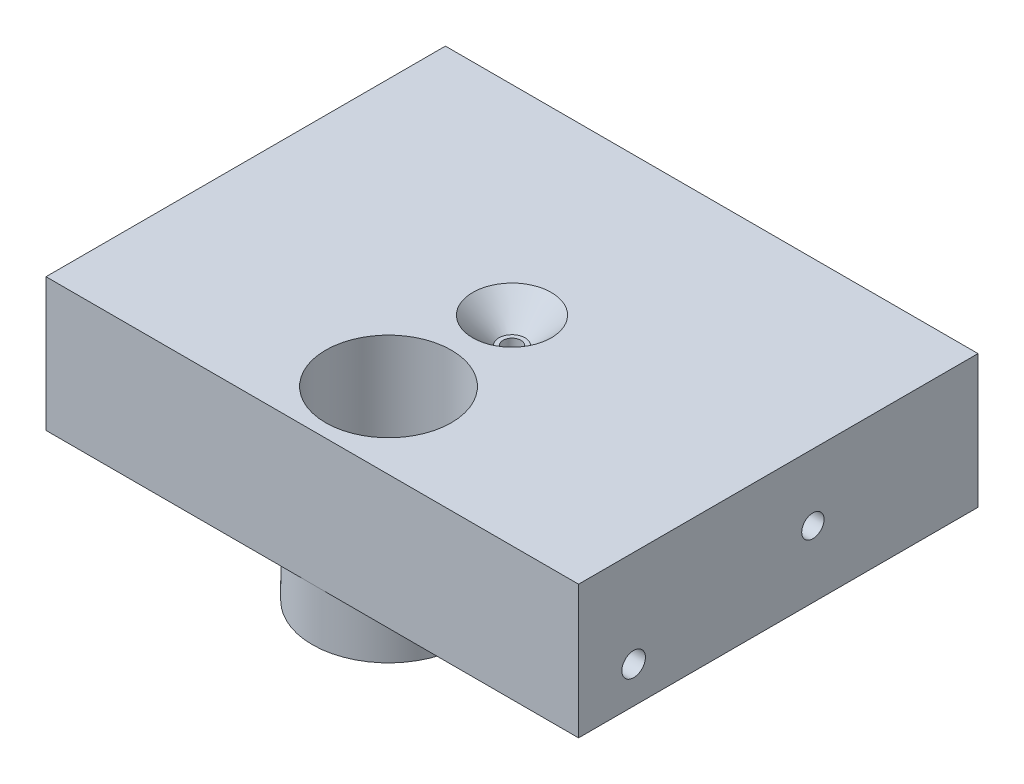
from build123d import *

# Parameters (mm, degrees)
SKETCH1_W                                        = 101.6
SKETCH1_H                                        = 76.2
BOSS_EXTRUDE1_DEPTH                              = 25.4
CBORE_FOR_M3_HEX_HEAD_MACHINE_SCREW1_D           = 3.4
CBORE_FOR_M3_HEX_HEAD_MACHINE_SCREW1_DEPTH       = 25.4
CBORE_FOR_M3_HEX_HEAD_MACHINE_SCREW1_CBORE_D     = 8.4
CBORE_FOR_M3_HEX_HEAD_MACHINE_SCREW1_CBORE_DEPTH = 2.3
SKETCH9_R                                        = 7.5
CUT_EXTRUDE1_DEPTH                               = 5
CUT_EXTRUDE1_TAPER                               = 45
SKETCH12_R                                       = 5
CUT_EXTRUDE3_DEPTH                               = 10
SKETCH13_R                                       = 2.1336
CUT_EXTRUDE4_DEPTH                               = 102.6
CUT_EXTRUDE5_REACH                               = 27.4
SKETCH14_R                                       = 12
SKETCH14_2_R                                     = 14.54
SKETCH14_2_R_2                                   = 12
EXTRUDE_THIN1_DEPTH                              = 10
SKETCH15_R                                       = 2.25
CUT_EXTRUDE6_DEPTH                               = 10


with BuildPart() as part:
    # Sketch1 → Boss-Extrude1 (new body)
    with BuildSketch(Plane(origin=(0, 0, 0), x_dir=(1, 0, 0), z_dir=(0, 1, 0))):
        Rectangle(SKETCH1_W, SKETCH1_H)
    extrude(amount=BOSS_EXTRUDE1_DEPTH)

    # CBORE for M3 Hex Head Machine Screw1
    with Locations(Plane(origin=(0, 0, 0), x_dir=(-1, 0, 0), z_dir=(0, -1, 0))):
        with Locations((0, 0)):
            CounterBoreHole(CBORE_FOR_M3_HEX_HEAD_MACHINE_SCREW1_D / 2, CBORE_FOR_M3_HEX_HEAD_MACHINE_SCREW1_CBORE_D / 2, CBORE_FOR_M3_HEX_HEAD_MACHINE_SCREW1_CBORE_DEPTH, depth=CBORE_FOR_M3_HEX_HEAD_MACHINE_SCREW1_DEPTH)

    # Sketch9 → Cut-Extrude1 (cut)
    with BuildSketch(Plane(origin=(0, 25.4, 0), x_dir=(1, 0, 0), z_dir=(0, 1, 0))):
        Circle(SKETCH9_R)
    extrude(amount=-CUT_EXTRUDE1_DEPTH, taper=CUT_EXTRUDE1_TAPER, mode=Mode.SUBTRACT)

    # Sketch12 → Cut-Extrude3 (cut)
    with BuildSketch(Plane(origin=(0, 25.4, 0), x_dir=(1, 0, 0), z_dir=(0, 1, 0))):
        with Locations((0, -20)):
            Circle(SKETCH12_R)
    extrude(amount=-CUT_EXTRUDE3_DEPTH, mode=Mode.SUBTRACT)

    # Sketch13 → Cut-Extrude4 (cut, through all)
    with BuildSketch(Plane.ZY.offset(50.8)):
        with Locations((-6.604, 12.7)):
            Circle(SKETCH13_R)
    extrude(amount=-CUT_EXTRUDE4_DEPTH, mode=Mode.SUBTRACT)

    # Sketch14 → Cut-Extrude5 (cut, up to next)
    with BuildSketch(Plane(origin=(0, 0, 0), x_dir=(-1, 0, 0), z_dir=(0, -1, 0)), mode=Mode.PRIVATE) as cut_extrude5_sk1:
        with Locations((0, -23.56)):
            Circle(SKETCH14_R)
    cut_extrude5_tool1 = extrude(cut_extrude5_sk1.sketch, amount=-CUT_EXTRUDE5_REACH, mode=Mode.PRIVATE) & part.part
    add(cut_extrude5_tool1.solids().sort_by_distance((0, 0, 23.56))[0], mode=Mode.SUBTRACT)

    # Sketch14_2 → Extrude-Thin1 (add)
    with BuildSketch(Plane(origin=(0, 0, 0), x_dir=(-1, 0, 0), z_dir=(0, -1, 0))):
        with Locations((0, -23.56)):
            Circle(SKETCH14_2_R)
        with Locations((0, -23.56)):
            Circle(SKETCH14_2_R_2, mode=Mode.SUBTRACT)
    extrude(amount=EXTRUDE_THIN1_DEPTH)

    # Sketch15 → Cut-Extrude6 (cut)
    with BuildSketch(Plane.ZY.offset(50.8)):
        with Locations((27.596, 6.95)):
            Circle(SKETCH15_R)
    cut_extrude6 = extrude(amount=-CUT_EXTRUDE6_DEPTH, mode=Mode.SUBTRACT)

    # Mirror1: Cut-Extrude6 across plane
    add(cut_extrude6.mirror(Plane(origin=(0, 0, 0), x_dir=(0, 0, 1), z_dir=(1, 0, 0))), mode=Mode.SUBTRACT)


solid = part.part
